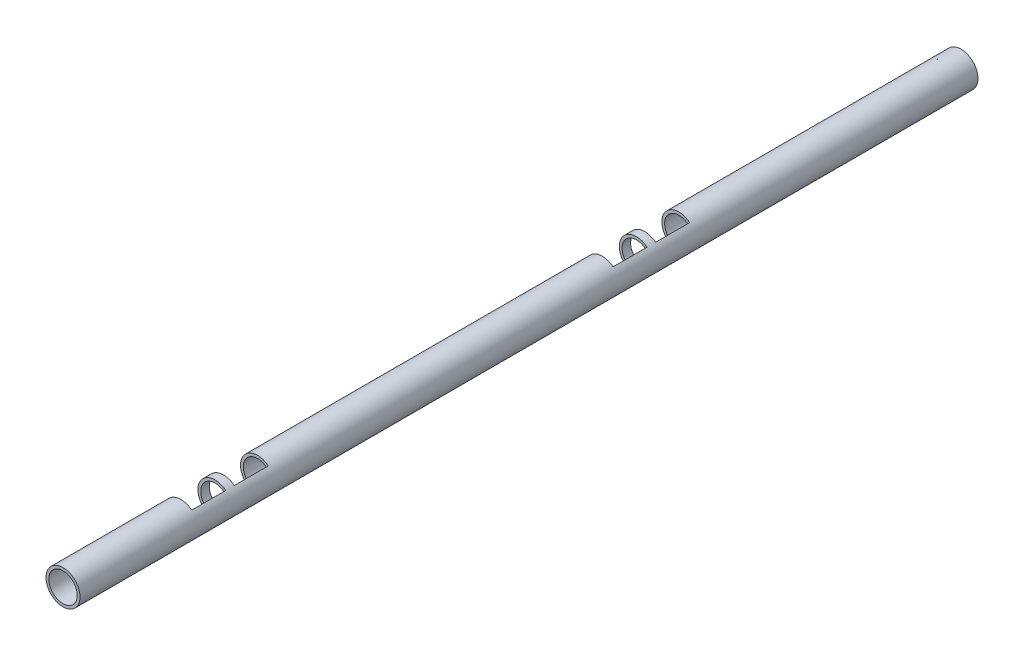
from build123d import *

# Parameters (mm, degrees)
SURFACE_EXTRUDE1_1_DEPTH   = 1.866
SURFACE_TRIM1_TOOL_2_BACK  = 3.327
SURFACE_TRIM1_TOOL_2_DEPTH = 6.654
THICKEN2_T1                = 0.101386
LPATTERN3_COUNT            = 2
LPATTERN3_PITCH            = 1.555
BOSS_EXTRUDE1_DEPTH        = 10
BOSS_EXTRUDE2_DEPTH        = 2
SKETCH7_R                  = 0.2
CUT_EXTRUDE2_DEPTH         = 11.038613849
LPATTERN4_COUNT            = 2
LPATTERN4_PITCH            = 15.4
SKETCH9_R                  = 0.622
SKETCH9_R_2                = 0.520614
BOSS_EXTRUDE3_DEPTH        = 2


with BuildPart() as body_1:
    # Surface-Extrude1: a surface, the sketch's curves swept straight by 1.866 mm
    with BuildLine(Plane.XY, mode=Mode.PRIVATE) as surface_extrude1_1_path:
        ThreePointArc((0.622, 0), (0, 0.622), (-0.622, 0))
    surface_extrude1_1 = Shell.extrude(surface_extrude1_1_path.wire(), (0 * SURFACE_EXTRUDE1_1_DEPTH, 0 * SURFACE_EXTRUDE1_1_DEPTH, 1 * SURFACE_EXTRUDE1_1_DEPTH))
    # Surface-Trim1 tool: a surface, the sketch's curves swept straight by 6.654 mm
    with BuildLine(Plane(origin=(0, 0, 0), x_dir=(1, 0, 0), z_dir=(0, 1, 0)).offset(-SURFACE_TRIM1_TOOL_2_BACK), mode=Mode.PRIVATE) as surface_trim1_tool_2_path:
        Line((-0.622, -1.555), (0.3932, -1.555))
        Line((0.3932, -1.555), (0.3932, -0.311))
        Line((0.3932, -0.311), (-0.622, -0.311))
    surface_trim1_tool_2 = Shell.extrude(surface_trim1_tool_2_path.wire(), (0 * SURFACE_TRIM1_TOOL_2_DEPTH, 1 * SURFACE_TRIM1_TOOL_2_DEPTH, 0 * SURFACE_TRIM1_TOOL_2_DEPTH))
    # Surface-Trim1: the surface trimmed, the side behind the tool kept
    surface_trim1_3 = split(surface_extrude1_1.faces()[0], bisect_by=surface_trim1_tool_2, keep=Keep.BOTTOM).faces()[0]
    add(Solid.thicken(surface_trim1_3, THICKEN2_T1))


with BuildPart() as lpattern3_1:
    # LPattern3: pattern copy
    add(body_1.part.moved(Location(Vector(0, 0, 1) * (1 * LPATTERN3_PITCH))))

    # Combine1: union body 1
    add(body_1.part)

    # Sketch5 → Boss-Extrude1 (add)
    with BuildSketch(Plane(origin=(0, 0, 0), x_dir=(-1, 0, 0), z_dir=(0, 0, -1))):
        with BuildLine():
            Line((-0.622, 0), (-0.520614, 0))
            ThreePointArc((-0.520614, 0), (0, 0.520614), (0.520614, 0))
            Line((0.520614, 0), (0.622, 0))
            ThreePointArc((0.622, 0), (0, 0.622), (-0.622, 0))
        make_face()
    extrude(amount=BOSS_EXTRUDE1_DEPTH)

    # Sketch6 → Boss-Extrude2 (add)
    with BuildSketch(Plane.XY.offset(3.421)):
        with BuildLine():
            Line((-0.622, 0), (-0.520614, 0))
            ThreePointArc((-0.520614, 0), (0, 0.520614), (0.520614, 0))
            Line((0.520614, 0), (0.622, 0))
            ThreePointArc((0.622, 0), (0, 0.622), (-0.622, 0))
        make_face()
    extrude(amount=BOSS_EXTRUDE2_DEPTH)

    # Sketch7 → Cut-Extrude2 (cut, through all)
    with BuildSketch(Plane(origin=(0, 0, 0), x_dir=(0, 0, -1), z_dir=(1, 0, 0))):
        with Locations((-4.61, 0)):
            Circle(SKETCH7_R)
    extrude(amount=-CUT_EXTRUDE2_DEPTH, mode=Mode.SUBTRACT)

    # Mirror1: LPattern3_1 across face


with BuildPart() as lpattern3_1_1:
    add(lpattern3_1.part)
    add(lpattern3_1.part.mirror(Plane(origin=(0.571307, 0, -2.2895), x_dir=(0, 0, 1), z_dir=(0, -1, 0))))


with BuildPart() as lpattern4_1:
    # LPattern4: pattern copy
    add(lpattern3_1_1.part.moved(Location(Vector(0, 0, -1) * (1 * LPATTERN4_PITCH))))

    # Combine2: union LPattern3_1
    add(lpattern3_1_1.part)

    # Sketch9 → Boss-Extrude3 (add)
    with BuildSketch(Plane.XY.offset(5.421)):
        Circle(SKETCH9_R)
        Circle(SKETCH9_R_2, mode=Mode.SUBTRACT)
    extrude(amount=BOSS_EXTRUDE3_DEPTH)


solid = lpattern4_1.part
